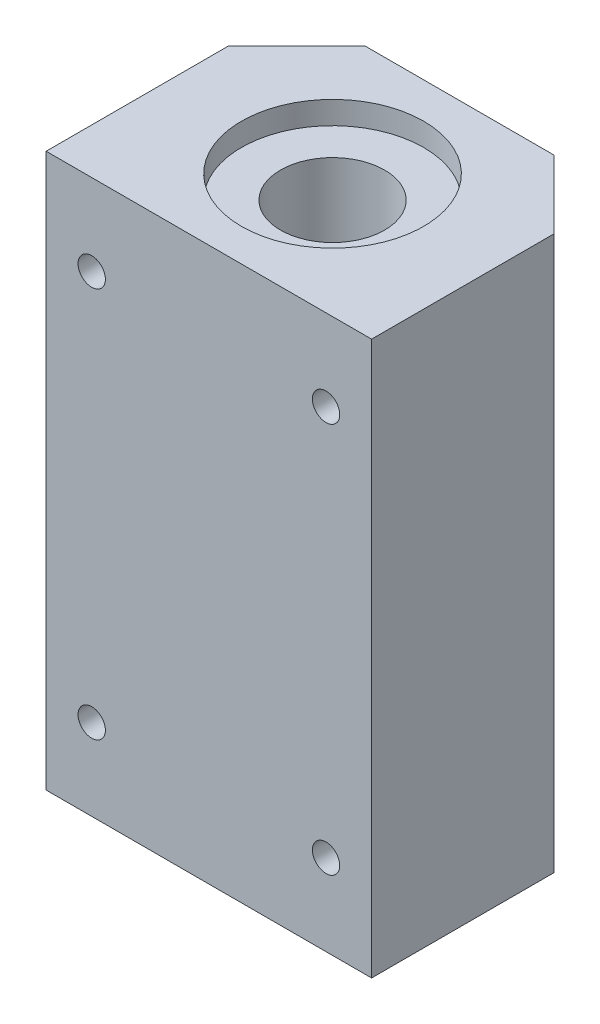
from build123d import *

# Parameters (mm, degrees)
SKETCH1_W           = 50
SKETCH1_H           = 85
BOSS_EXTRUDE1_DEPTH = 38.5
M5_TAPPED_HOLE1_D   = 4.2
SKETCH6_R           = 14
CUT_EXTRUDE1_DEPTH  = 86
SKETCH8_R           = 14
SKETCH8_R_2         = 8
BOSS_EXTRUDE2_DEPTH = 39


with BuildPart() as part:
    # Sketch1 → Boss-Extrude1 (new body)
    with BuildSketch(Plane.XY):
        Rectangle(SKETCH1_W, SKETCH1_H)
    extrude(amount=BOSS_EXTRUDE1_DEPTH)

    # M5 Tapped Hole1 (through all)
    with Locations(Plane.XY.offset(38.5)):
        with Locations((-18, 30), (18, 30), (18, -30), (-18, -30)):
            Hole(M5_TAPPED_HOLE1_D / 2)

    # Sketch6 → Cut-Extrude1 (cut, through all)
    with BuildSketch(Plane(origin=(0, 42.5, 0), x_dir=(1, 0, 0), z_dir=(0, 1, 0))):
        with Locations((0, -19.5)):
            Circle(SKETCH6_R)
        Polygon((-25, -10.5), (-14.5, 0), (-25, 0), align=None)
        Polygon((25, -10.5), (14.5, 0), (25, 0), align=None)
    extrude(amount=-CUT_EXTRUDE1_DEPTH, mode=Mode.SUBTRACT)

    # Sketch8 → Boss-Extrude2 (add, symmetric)
    with BuildSketch(Plane(origin=(0, 0, 0), x_dir=(-1, 0, 0), z_dir=(0, -1, 0))):
        with Locations((0, -19.5)):
            Circle(SKETCH8_R)
        with Locations((0, -19.5)):
            Circle(SKETCH8_R_2, mode=Mode.SUBTRACT)
    extrude(amount=BOSS_EXTRUDE2_DEPTH, both=True)


solid = part.part
